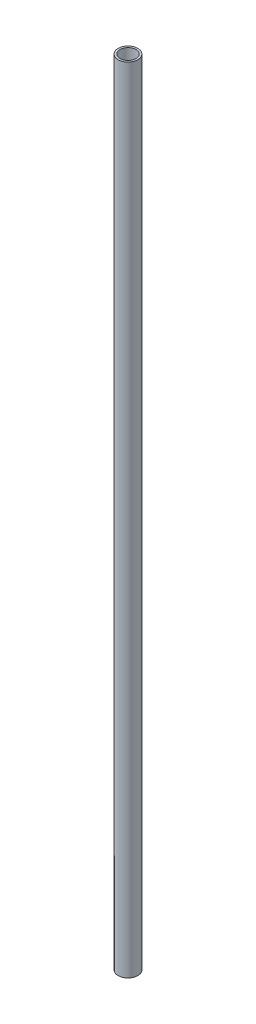
from build123d import *

# Parameters (mm, degrees)
SKETCH1_R           = 0.31
SKETCH1_R_2         = 0.25
BOSS_EXTRUDE1_DEPTH = 25


with BuildPart() as part:
    # Sketch1 → Boss-Extrude1 (new body)
    with BuildSketch(Plane(origin=(0, 0, 0), x_dir=(1, 0, 0), z_dir=(0, 1, 0))):
        Circle(SKETCH1_R)
        Circle(SKETCH1_R_2, mode=Mode.SUBTRACT)
    extrude(amount=BOSS_EXTRUDE1_DEPTH)


solid = part.part
